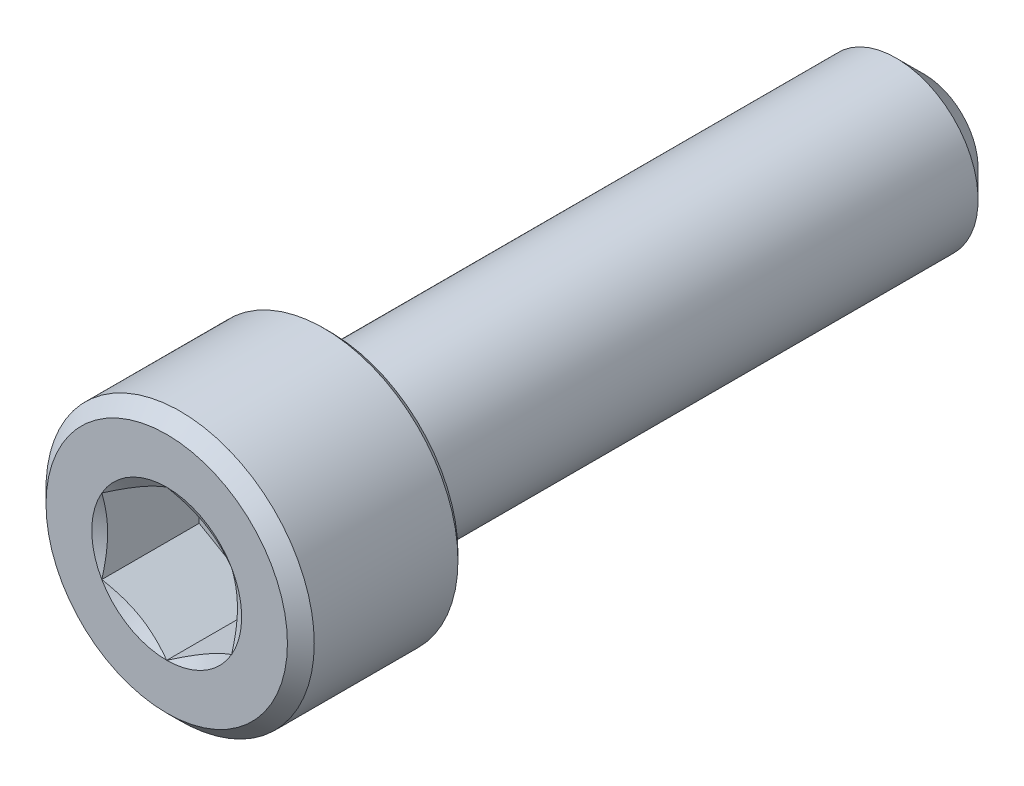
from build123d import *

# Parameters (mm, degrees)
CUT_EXTRUDE1_DEPTH = 2.08359375
CHAMFER1_SIZE      = 0.28702
CHAMFER2_SIZE      = 0.14351


with BuildPart() as part:
    # Sketch2 → Revolve1 (revolve)
    with BuildSketch(Plane(origin=(0, 0, 0), x_dir=(0, 0, -1), z_dir=(1, 0, 0))):
        Polygon((8.1026, 1.1572875), (7.5072875, 1.7526), (-4.5974, 1.7526), (-4.5974, 2.8702), (-8.1026, 2.8702), (-8.1026, 0), (8.1026, 0), align=None)
    revolve(axis=Axis((0, 0, -8.1026), (0, 0, 1)))

    # Sketch4 → Cut-Extrude1 (cut)
    with BuildSketch(Plane.XY.offset(8.1026)):
        Polygon((0, 1.603951217), (-1.3890625, 0.801975608), (-1.3890625, -0.801975608), (0, -1.603951217), (1.3890625, -0.801975608), (1.3890625, 0.801975608), align=None)
    extrude(amount=-CUT_EXTRUDE1_DEPTH, mode=Mode.SUBTRACT)

    # Cut-Extrude2 cone 1 section (through the dimple's axis) → Cut-Extrude2 (revolve, cut)
    with BuildSketch(Plane(origin=(0, 0, 8.1026), x_dir=(0, -1, 0), z_dir=(1, 0, 0))):
        Polygon((0, 0), (1.603951217, 0), (0, 0.926041667), align=None)
    revolve(axis=Axis((0, 0, 8.1026), (0, 0, -1)), mode=Mode.SUBTRACT)

    # Chamfer1
    chamfer1_edges = [part.edges().sort_by_distance(p)[0] for p in [
        (0, -2.8702, 8.1026),
    ]]
    chamfer(chamfer1_edges, length=CHAMFER1_SIZE)

    # Chamfer2
    chamfer2_edges = [part.edges().sort_by_distance(p)[0] for p in [
        (0, -2.8702, 4.5974),
    ]]
    chamfer(chamfer2_edges, length=CHAMFER2_SIZE)


solid = part.part
